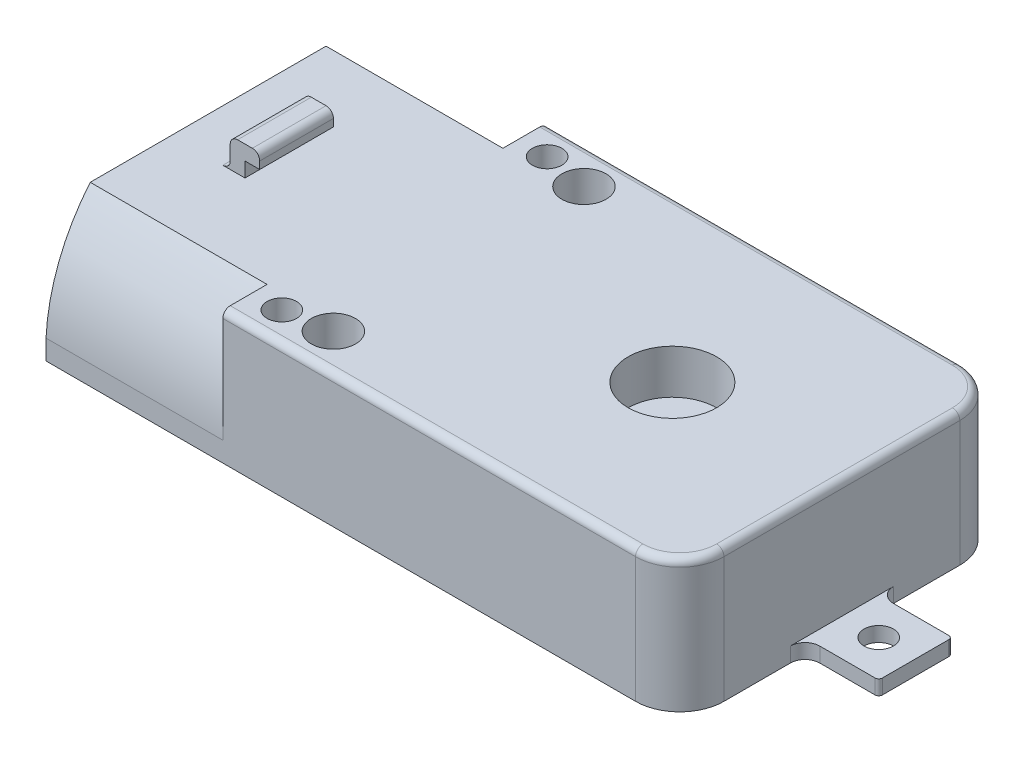
from build123d import *

# Parameters (mm, degrees)
BOSS_EXTRUDE2_DEPTH = 9
SKETCH4_W           = 5
SKETCH4_H           = 1
BOSS_EXTRUDE3_DEPTH = 5
SKETCH5_R           = 1
CUT_EXTRUDE1_DEPTH  = 5
FILLET1_R           = 1
FILLET2_R           = 1
FILLET3_R           = 3
FILLET4_R           = 3
BOSS_EXTRUDE4_DEPTH = 12
FILLET5_R           = 0.5
FILLET6_R           = 0.25
SKETCH8_R           = 3
CUT_EXTRUDE3_DEPTH  = 3
SKETCH9_R           = 0.75
CUT_EXTRUDE4_DEPTH  = 3
SKETCH10_R          = 1.5
CUT_EXTRUDE7_DEPTH  = 44.13930922
SKETCH12_R          = 1
CUT_EXTRUDE8_DEPTH  = 5
SKETCH13_W          = 1
SKETCH13_H          = 5
BOSS_EXTRUDE5_DEPTH = 2
SKETCH14_W          = 5
SKETCH14_H          = 1
BOSS_EXTRUDE6_DEPTH = 1
FILLET7_R           = 0.5
FILLET8_R           = 0.5
FILLET9_R           = 0.5
CUT_EXTRUDE9_DEPTH  = 10


with BuildPart() as part:
    # Sketch2 → Boss-Extrude2 (new body)
    with BuildSketch(Plane(origin=(0, 0, 0), x_dir=(1, 0, 0), z_dir=(0, 1, 0))):
        Polygon((0, 11), (31, 11), (31, 13.5), (31, 22), (0, 22), align=None)
        Polygon((31, 8.5), (31, 11), (0, 11), (0, 0), (31, 0), align=None)
    extrude(amount=BOSS_EXTRUDE2_DEPTH)

    # Sketch4 → Boss-Extrude3 (add)
    with BuildSketch(Plane(origin=(31, 0, 0), x_dir=(0, 0, -1), z_dir=(1, 0, 0))):
        with Locations((11, 0.5)):
            Rectangle(SKETCH4_W, SKETCH4_H)
    extrude(amount=BOSS_EXTRUDE3_DEPTH)

    # Sketch5 → Cut-Extrude1 (cut)
    with BuildSketch(Plane(origin=(0, 1, 0), x_dir=(1, 0, 0), z_dir=(0, 1, 0))):
        with Locations(Location((33.5, 11, 0), (0, 0, 270))):
            Circle(SKETCH5_R)
    extrude(amount=-CUT_EXTRUDE1_DEPTH, mode=Mode.SUBTRACT)

    # Fillet1
    fillet1_edges = [part.edges().sort_by_distance(p)[0] for p in [
        (31, 0.5, -8.5),
    ]]
    fillet(fillet1_edges, radius=FILLET1_R)

    # Fillet2
    fillet2_edges = [part.edges().sort_by_distance(p)[0] for p in [
        (31, 0.5, -13.5),
    ]]
    fillet(fillet2_edges, radius=FILLET2_R)

    # Fillet3
    fillet3_edges = [part.edges().sort_by_distance(p)[0] for p in [
        (31, 4.5, 0),
    ]]
    fillet(fillet3_edges, radius=FILLET3_R)

    # Fillet4
    fillet4_edges = [part.edges().sort_by_distance(p)[0] for p in [
        (31, 4.5, -22),
    ]]
    fillet(fillet4_edges, radius=FILLET4_R)

    # Sketch6 → Boss-Extrude4 (add)
    with BuildSketch(Plane.ZY):
        with BuildLine():
            Line((-22, 0), (-11, 0))
            Line((-11, 0), (-11, 9))
            Line((-11, 9), (-19, 9))
            ThreePointArc((-19, 9), (-21.121122912, 5.415884648), (-22, 1.344936316))
            Line((-22, 1.344936316), (-22, 0))
        make_face()
        with BuildLine():
            Line((-11, 9), (-11, 0))
            Line((-11, 0), (0, 0))
            Line((0, 0), (0, 1.344936316))
            ThreePointArc((0, 1.344936316), (-0.878877088, 5.415884648), (-3, 9))
            Line((-3, 9), (-11, 9))
        make_face()
    extrude(amount=BOSS_EXTRUDE4_DEPTH)

    # Fillet5
    fillet5_edges = [part.edges().sort_by_distance(p)[0] for p in [
        (14, 9, -22),
        (30.121320344, 9, -21.121320344),
        (31, 9, -11),
        (30.121320344, 9, -0.878679656),
        (14, 9, 0),
    ]]
    fillet(fillet5_edges, radius=FILLET5_R)

    # Fillet6
    fillet6_edges = [part.edges().sort_by_distance(p)[0] for p in [
        (36, 0.5, -13.5),
        (36, 0.5, -8.5),
    ]]
    fillet(fillet6_edges, radius=FILLET6_R)

    # Sketch8 → Cut-Extrude3 (cut)
    with BuildSketch(Plane(origin=(0, 9, 0), x_dir=(1, 0, 0), z_dir=(0, 1, 0))):
        with Locations(Location((19.5, 11, 0), (0, 0, 270))):
            Circle(SKETCH8_R)
    extrude(amount=-CUT_EXTRUDE3_DEPTH, mode=Mode.SUBTRACT)

    # Sketch9 → Cut-Extrude4 (cut)
    with BuildSketch(Plane(origin=(0, 6, 0), x_dir=(1, 0, 0), z_dir=(0, 1, 0))):
        with Locations(Location((19.5, 11, 0), (0, 0, 270))):
            Circle(SKETCH9_R)
    extrude(amount=-CUT_EXTRUDE4_DEPTH, mode=Mode.SUBTRACT)

    # Sketch10 → Cut-Extrude7 (cut, through all)
    with BuildSketch(Plane(origin=(0, 9, 0), x_dir=(1, 0, 0), z_dir=(0, 1, 0))):
        with Locations(Location((5, 19.5, 0), (0, 0, 90))):
            Circle(SKETCH10_R)
        with Locations(Location((5, 2.5, 0), (0, 0, 270))):
            Circle(SKETCH10_R)
    extrude(amount=-CUT_EXTRUDE7_DEPTH, mode=Mode.SUBTRACT)

    # Sketch12 → Cut-Extrude8 (cut)
    with BuildSketch(Plane(origin=(0, 9, 0), x_dir=(1, 0, 0), z_dir=(0, 1, 0))):
        with Locations(Location((2, 2, 0), (0, 0, 270))):
            Circle(SKETCH12_R)
        with Locations(Location((2, 20, 0), (0, 0, 270))):
            Circle(SKETCH12_R)
    extrude(amount=-CUT_EXTRUDE8_DEPTH, mode=Mode.SUBTRACT)

    # Sketch13 → Boss-Extrude5 (add)
    with BuildSketch(Plane(origin=(0, 9, 0), x_dir=(1, 0, 0), z_dir=(0, 1, 0))):
        with Locations((-7.5, 11)):
            Rectangle(SKETCH13_W, SKETCH13_H)
    extrude(amount=BOSS_EXTRUDE5_DEPTH)

    # Sketch14 → Boss-Extrude6 (add)
    with BuildSketch(Plane(origin=(-7, 0, 0), x_dir=(0, 0, -1), z_dir=(1, 0, 0))):
        with Locations((11, 10.5)):
            Rectangle(SKETCH14_W, SKETCH14_H)
    extrude(amount=BOSS_EXTRUDE6_DEPTH)

    # Fillet7
    fillet7_edges = [part.edges().sort_by_distance(p)[0] for p in [
        (-8, 11, -11),
    ]]
    fillet(fillet7_edges, radius=FILLET7_R)

    # Fillet8
    fillet8_edges = [part.edges().sort_by_distance(p)[0] for p in [
        (-8, 9, -11),
    ]]
    fillet(fillet8_edges, radius=FILLET8_R)

    # Fillet9
    fillet9_edges = [part.edges().sort_by_distance(p)[0] for p in [
        (-6, 11, -11),
    ]]
    fillet(fillet9_edges, radius=FILLET9_R)

    # Sketch16 → Cut-Extrude9 (cut)
    with BuildSketch(Plane.ZY.offset(12)):
        with BuildLine():
            Line((-18.232108037, 8.359420628), (-3.767891963, 8.359420628))
            ThreePointArc((-3.767891963, 8.359420628), (-1.809932353, 5.051006457), (-0.998661194, 1.293207997))
            Line((-0.998661194, 1.293207997), (-0.998661194, 0))
            Line((-0.998661194, 0), (-21, 0))
            Line((-21, 0), (-21.001338806, 1.293207997))
            ThreePointArc((-21.001338806, 1.293207997), (-20.190067647, 5.051006457), (-18.232108037, 8.359420628))
        make_face()
    extrude(amount=-CUT_EXTRUDE9_DEPTH, mode=Mode.SUBTRACT)


solid = part.part
